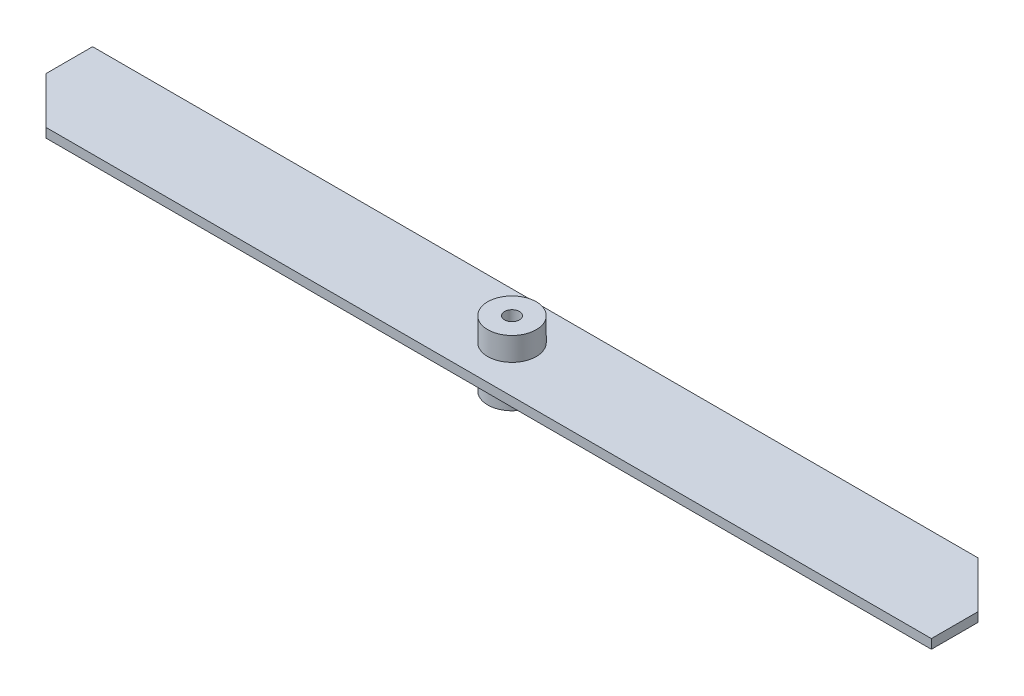
from build123d import *

# Parameters (mm, degrees)
SKETCH_1_R          = 1.585
EXTRUDE_1_DEPTH     = 2
SKETCH_2_R          = 5.2
EXTRUDE_2_DEPTH     = 7
SKETCH_3_R          = 1.585
CUT_EXTRUDE_1_DEPTH = 10


with BuildPart() as part:
    # 草图1 → 凸台-拉伸1 (new body)
    with BuildSketch(Plane(origin=(0, 0, 0), x_dir=(1, 0, 0), z_dir=(0, 1, 0))):
        Polygon((90, 10), (100, 0), (100, -10), (-90, -10), (-100, 0), (-100, 10), align=None)
        Circle(SKETCH_1_R, mode=Mode.SUBTRACT)
    extrude(amount=EXTRUDE_1_DEPTH)

    # 草图2 → 凸台-拉伸2 (add, symmetric)
    with BuildSketch(Plane.XZ):
        Circle(SKETCH_2_R)
    extrude(amount=EXTRUDE_2_DEPTH, both=True)

    # 草图3 → 切除-拉伸1 (cut)
    with BuildSketch(Plane(origin=(0, 7, 0), x_dir=(1, 0, 0), z_dir=(0, 1, 0))):
        Circle(SKETCH_3_R)
    extrude(amount=-CUT_EXTRUDE_1_DEPTH, mode=Mode.SUBTRACT)


solid = part.part
